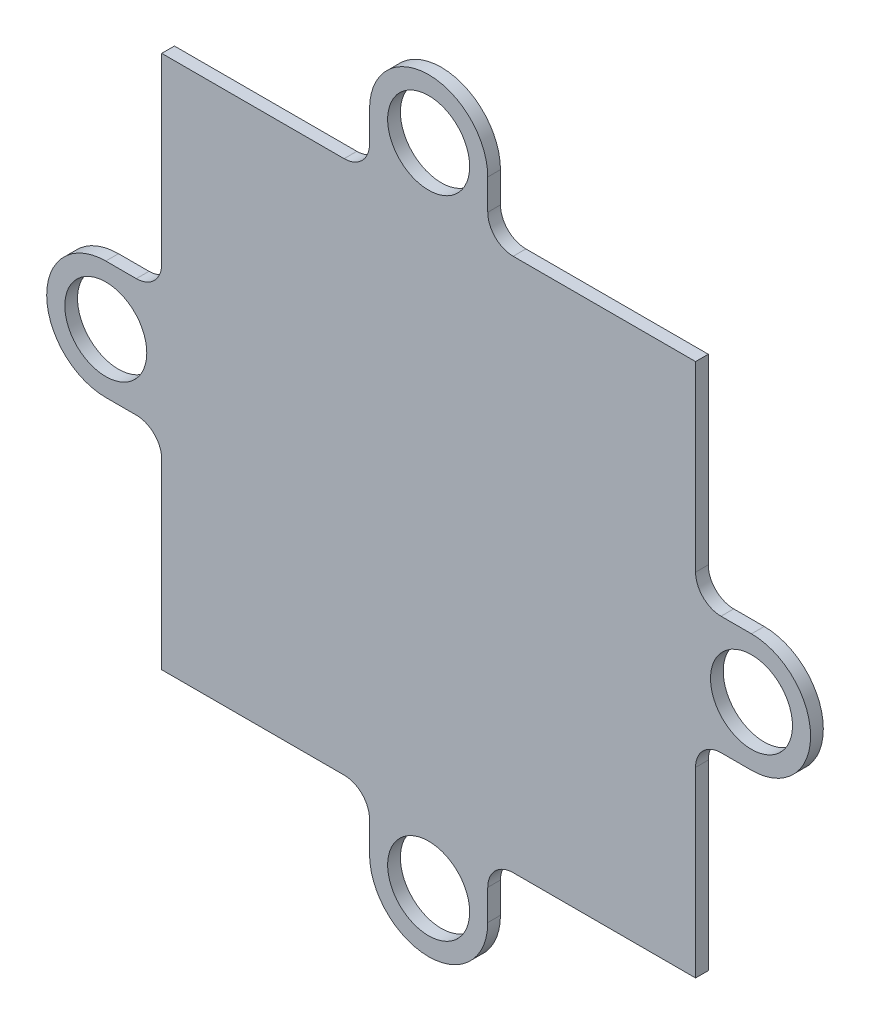
from build123d import *

# Parameters (mm, degrees)
SKETCH1_R           = 3.225
BOSS_EXTRUDE1_DEPTH = 1


with BuildPart() as part:
    # Sketch1 → Boss-Extrude1 (new body)
    with BuildSketch(Plane.XY):
        with BuildLine():
            ThreePointArc((4.65, 25.4), (0, 30.05), (-4.65, 25.4))
            Line((-4.65, 25.4), (-4.65, 23))
            ThreePointArc((-4.65, 23), (-5.235786438, 21.585786438), (-6.65, 21))
            Line((-6.65, 21), (-8.759132098, 21))
            Line((-8.759132098, 21), (-21, 21))
            Line((-21, 21), (-21, 7.133487824))
            Line((-21, 7.133487824), (-21, 6.65))
            ThreePointArc((-21, 6.65), (-21.585786438, 5.235786438), (-23, 4.65))
            Line((-23, 4.65), (-25.4, 4.65))
            ThreePointArc((-25.4, 4.65), (-30.05, 0), (-25.4, -4.65))
            Line((-25.4, -4.65), (-23, -4.65))
            ThreePointArc((-23, -4.65), (-21.585786438, -5.235786438), (-21, -6.65))
            Line((-21, -6.65), (-21, -8.759132098))
            Line((-21, -8.759132098), (-21, -21))
            Line((-21, -21), (-7.133487824, -21))
            Line((-7.133487824, -21), (-6.65, -21))
            ThreePointArc((-6.65, -21), (-5.235786438, -21.585786438), (-4.65, -23))
            Line((-4.65, -23), (-4.65, -25.4))
            ThreePointArc((-4.65, -25.4), (0, -30.05), (4.65, -25.4))
            Line((4.65, -25.4), (4.65, -23))
            ThreePointArc((4.65, -23), (5.235786438, -21.585786438), (6.65, -21))
            Line((6.65, -21), (8.759132098, -21))
            Line((8.759132098, -21), (21, -21))
            Line((21, -21), (21, -7.133487824))
            Line((21, -7.133487824), (21, -6.65))
            ThreePointArc((21, -6.65), (21.585786438, -5.235786438), (23, -4.65))
            Line((23, -4.65), (25.4, -4.65))
            ThreePointArc((25.4, -4.65), (30.05, 0), (25.4, 4.65))
            Line((25.4, 4.65), (23, 4.65))
            ThreePointArc((23, 4.65), (21.585786438, 5.235786438), (21, 6.65))
            Line((21, 6.65), (21, 8.759132098))
            Line((21, 8.759132098), (21, 21))
            Line((21, 21), (7.133487824, 21))
            Line((7.133487824, 21), (6.65, 21))
            ThreePointArc((6.65, 21), (5.235786438, 21.585786438), (4.65, 23))
            Line((4.65, 23), (4.65, 25.4))
        make_face()
        with Locations((0, -25.4)):
            Circle(SKETCH1_R, mode=Mode.SUBTRACT)
        with Locations((25.4, 0)):
            Circle(SKETCH1_R, mode=Mode.SUBTRACT)
        with Locations((-25.4, 0)):
            Circle(SKETCH1_R, mode=Mode.SUBTRACT)
        with Locations((0, 25.4)):
            Circle(SKETCH1_R, mode=Mode.SUBTRACT)
    extrude(amount=BOSS_EXTRUDE1_DEPTH)


solid = part.part
